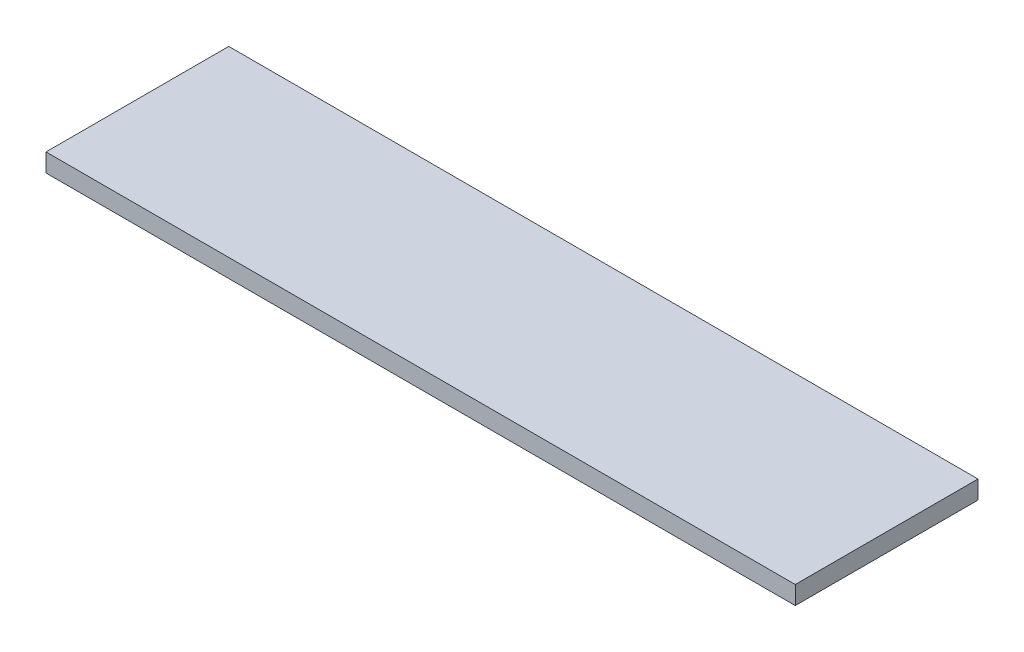
from build123d import *

# Parameters (mm, degrees)
SKETCH1_W           = 410
SKETCH1_H           = 100
BOSS_EXTRUDE1_DEPTH = 10


with BuildPart() as part:
    # Sketch1 → Boss-Extrude1 (new body)
    with BuildSketch(Plane(origin=(0, 0, 0), x_dir=(1, 0, 0), z_dir=(0, 1, 0))):
        Rectangle(SKETCH1_W, SKETCH1_H)
    extrude(amount=BOSS_EXTRUDE1_DEPTH)


solid = part.part
